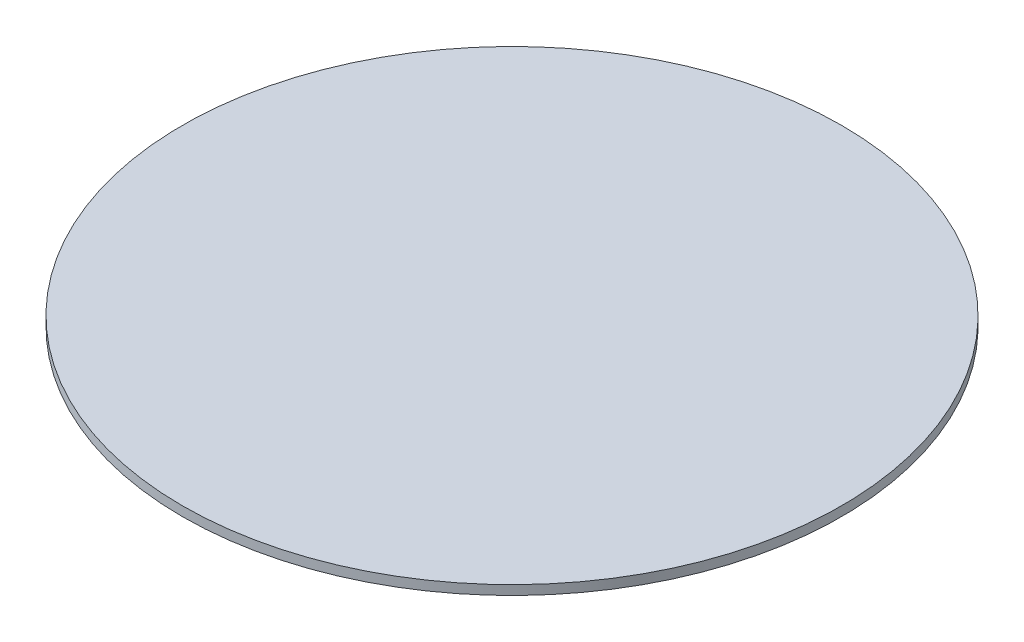
from build123d import *

# Parameters (mm, degrees)
SCHIZZO1_R                   = 10.5
ESTRUSIONE_ESTRUSIONE1_DEPTH = 0.3


with BuildPart() as part:
    # Schizzo1 → Estrusione-Estrusione1 (new body)
    with BuildSketch(Plane(origin=(0, 0, 0), x_dir=(1, 0, 0), z_dir=(0, 1, 0))):
        Circle(SCHIZZO1_R)
    extrude(amount=ESTRUSIONE_ESTRUSIONE1_DEPTH)


solid = part.part
